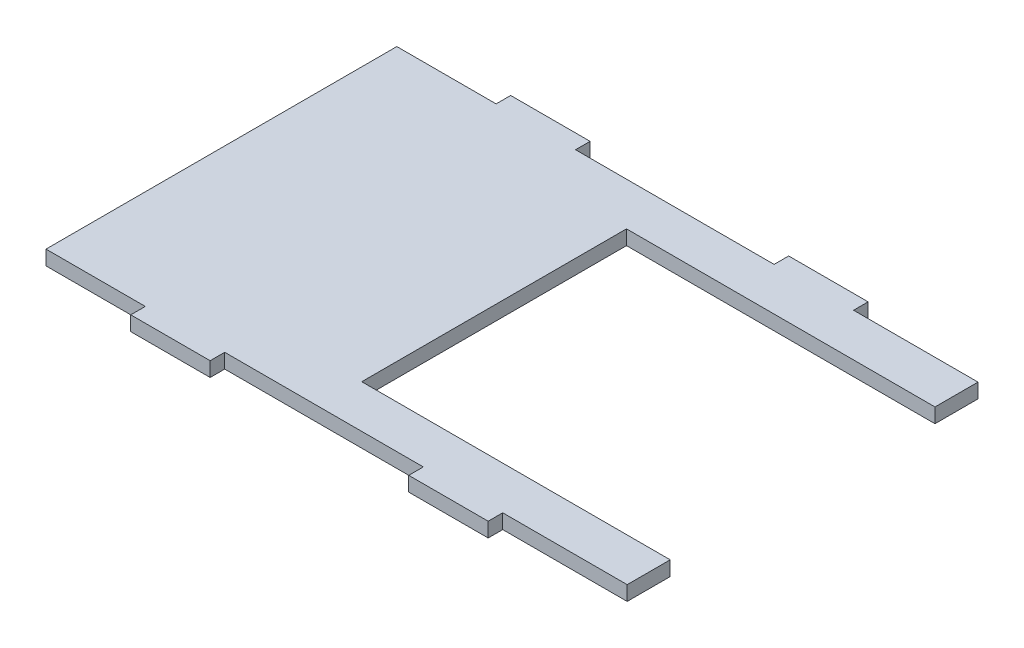
from build123d import *

# Parameters (mm, degrees)
BOSS_EXTRUDE1_DEPTH = 2.794


with BuildPart() as part:
    # Sketch2 → Boss-Extrude1 (new body)
    with BuildSketch(Plane(origin=(0, 0, 0), x_dir=(1, 0, 0), z_dir=(0, 1, 0))):
        Polygon((111.506, 59.055), (111.506, 67.31), (87.629999836, 67.31), (87.629999836, 70.104), (72.39, 70.104), (72.39, 67.31), (34.29, 67.31), (34.29, 70.104), (19.05, 70.104), (19.05, 67.31), (0, 67.31), (0, 0), (19.05, 0), (19.05, -2.794), (34.29, -2.794), (34.29, 0), (72.39, 0), (72.39, -2.794), (87.629999836, -2.794), (87.629999836, 0), (111.506, 0), (111.506, 8.255), (52.324, 8.255), (52.324, 59.055), align=None)
    extrude(amount=BOSS_EXTRUDE1_DEPTH)


solid = part.part
